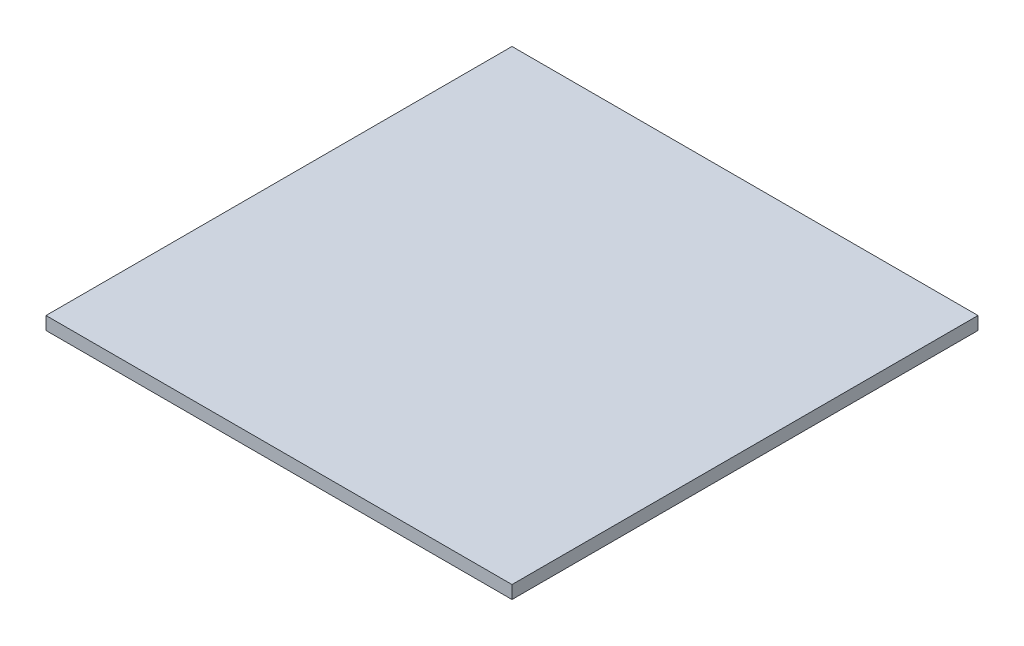
from build123d import *

# Parameters (mm, degrees)
SKETCH1_W           = 215
SKETCH1_H           = 215
BOSS_EXTRUDE1_DEPTH = 6


with BuildPart() as part:
    # Sketch1 → Boss-Extrude1 (new body)
    with BuildSketch(Plane(origin=(0, 0, 0), x_dir=(0, 0, -1), z_dir=(0, 1, 0))):
        with Locations((65.251596989, 74)):
            Rectangle(SKETCH1_W, SKETCH1_H)
    extrude(amount=BOSS_EXTRUDE1_DEPTH)


solid = part.part
